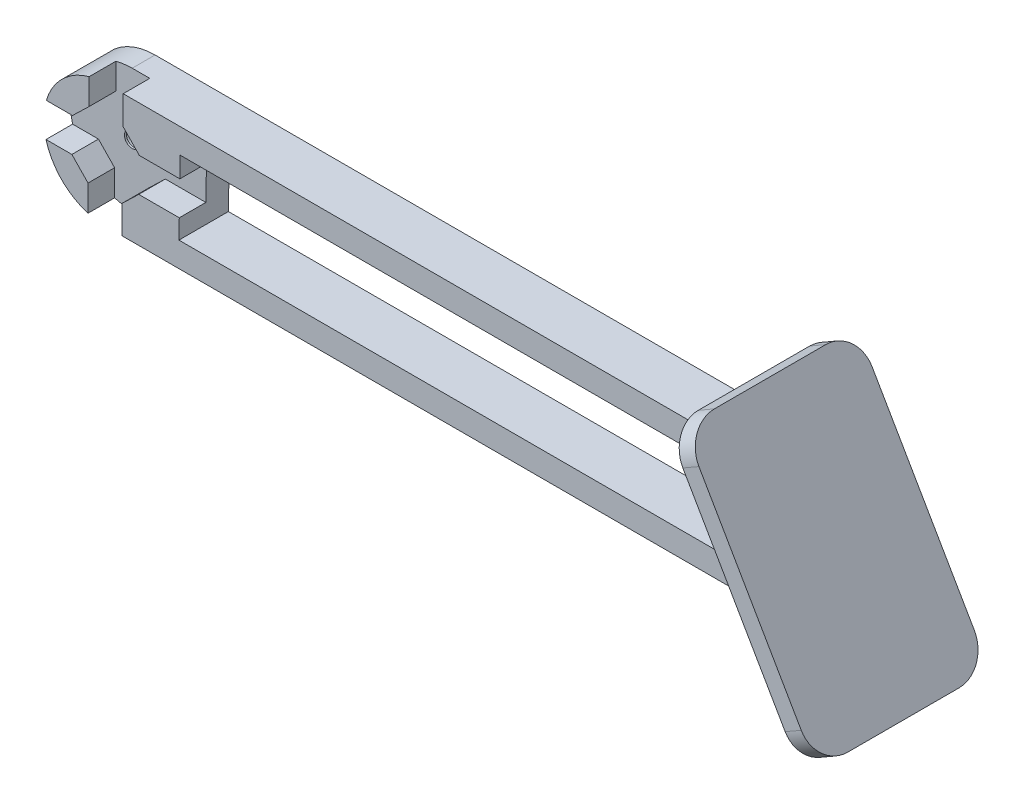
from build123d import *

# Parameters (mm, degrees)
BOSS_EXTRU_1_DEPTH       = 8
ESQUISSE13_R             = 4
ENL_V_MAT_EXTRU_9_DEPTH  = 4.3
ENL_V_MAT_EXTRU_10_DEPTH = 4.3
ESQUISSE15_R             = 2.5
ENL_V_MAT_EXTRU_11_DEPTH = 3.4
ENL_V_MAT_EXTRU_12_REACH = 6.6
ESQUISSE16_R             = 1.25
ESQUISSE17_W             = 10
ESQUISSE17_H             = 20
ENL_V_MAT_EXTRU_13_DEPTH = 10
ENL_V_MAT_EXTRU_15_DEPTH = 10
ESQUISSE20_W             = 28
ESQUISSE20_H             = 43.094010768
BOSS_EXTRU_2_DEPTH       = 3
ENL_V_MAT_EXTRU_16_REACH = 20
CONG_1_R                 = 5


with BuildPart() as part:
    # Esquisse1 → Boss.-Extru.1 (new body)
    with BuildSketch(Plane.XY):
        with BuildLine():
            Line((0, 0), (120, 0))
            ThreePointArc((120, 0), (130, 10), (120, 20))
            Line((120, 20), (0, 20))
            ThreePointArc((0, 20), (-10, 10), (0, 0))
        make_face()
    extrude(amount=BOSS_EXTRU_1_DEPTH)

    # Esquisse13 → Enlèv. mat.-Extru.9 (cut)
    with BuildSketch(Plane.XY.offset(8)):
        with Locations((0, 10)):
            Circle(ESQUISSE13_R)
    extrude(amount=-ENL_V_MAT_EXTRU_9_DEPTH, mode=Mode.SUBTRACT)

    # Esquisse14 → Enlèv. mat.-Extru.10 (cut)
    with BuildSketch(Plane.XY.offset(8)):
        Polygon((2.655377087, 4.544050257), (2.655377087, -2.008601379), (-2.844622913, -1.912365766), (-2.844622913, 4.640285869), (-5.455949743, 7.344622913), (-12.008601379, 7.344622913), (-11.912365766, 12.844622913), (-5.359714131, 12.844622913), (-2.655377087, 15.455949743), (-2.655377087, 22.008601379), (2.844622913, 21.912365766), (2.844622913, 15.359714131), (5.455949743, 12.655377087), (12.008601379, 12.655377087), (11.912365766, 7.155377087), (5.359714131, 7.155377087), align=None)
    extrude(amount=-ENL_V_MAT_EXTRU_10_DEPTH, mode=Mode.SUBTRACT)

    # Esquisse15 → Enlèv. mat.-Extru.11 (cut)
    with BuildSketch(Plane(origin=(0, 0, 0), x_dir=(-1, 0, 0), z_dir=(0, 0, -1))):
        with Locations((0, 10)):
            Circle(ESQUISSE15_R)
    extrude(amount=-ENL_V_MAT_EXTRU_11_DEPTH, mode=Mode.SUBTRACT)

    # Esquisse16 → Enlèv. mat.-Extru.12 (cut, up to next)
    with BuildSketch(Plane(origin=(0, 0, 3.4), x_dir=(-1, 0, 0), z_dir=(0, 0, -1)), mode=Mode.PRIVATE) as enl_v_mat_extru_12_sk1:
        with Locations((0, 10)):
            Circle(ESQUISSE16_R)
    enl_v_mat_extru_12_tool1 = extrude(enl_v_mat_extru_12_sk1.sketch, amount=-ENL_V_MAT_EXTRU_12_REACH, mode=Mode.PRIVATE) & part.part
    add(enl_v_mat_extru_12_tool1.solids().sort_by_distance((0, 10, 3.4))[0], mode=Mode.SUBTRACT)

    # Esquisse17 → Enlèv. mat.-Extru.13 (cut)
    with BuildSketch(Plane.XY.offset(8)):
        with Locations((125, 10)):
            Rectangle(ESQUISSE17_W, ESQUISSE17_H)
    extrude(amount=-ENL_V_MAT_EXTRU_13_DEPTH, mode=Mode.SUBTRACT)

    # Esquisse19 → Enlèv. mat.-Extru.15 (cut)
    with BuildSketch(Plane(origin=(0, 0, 0), x_dir=(-1, 0, 0), z_dir=(0, 0, -1))):
        Polygon((-131.547005384, 0), (-120, 0), (-108.452994616, 20), (-120, 20), align=None)
    extrude(amount=-ENL_V_MAT_EXTRU_15_DEPTH, mode=Mode.SUBTRACT)

    # Esquisse20 → Boss.-Extru.2 (add)
    with BuildSketch(Plane(origin=(90, 51.961524227, 0), x_dir=(0, 0, -1), z_dir=(0.866025404, 0.5, 0))):
        with Locations((-4, -48.452994616)):
            Rectangle(ESQUISSE20_W, ESQUISSE20_H)
    extrude(amount=-BOSS_EXTRU_2_DEPTH)

    # Esquisse21 → Enlèv. mat.-Extru.16 (cut, up to next)
    with BuildSketch(Plane.XY.offset(8), mode=Mode.PRIVATE) as enl_v_mat_extru_16_sk1:
        Polygon((11.857154921, 4), (109.607695155, 4), (102.679491924, 16), (12.06712353, 16), align=None)
    enl_v_mat_extru_16_tool1 = extrude(enl_v_mat_extru_16_sk1.sketch, amount=-ENL_V_MAT_EXTRU_16_REACH, mode=Mode.PRIVATE) & part.part
    add(enl_v_mat_extru_16_tool1.solids().sort_by_distance((59.074082, 9.924208, 8))[0], mode=Mode.SUBTRACT)

    # Congé1
    cong_1_edges = [part.edges().sort_by_distance(p)[0] for p in [
        (123.700961894, -9.410254038, 18),
        (102.153956511, 27.910254038, 18),
        (102.153956511, 27.910254038, -10),
        (123.700961894, -9.410254038, -10),
    ]]
    fillet(cong_1_edges, radius=CONG_1_R)


solid = part.part
